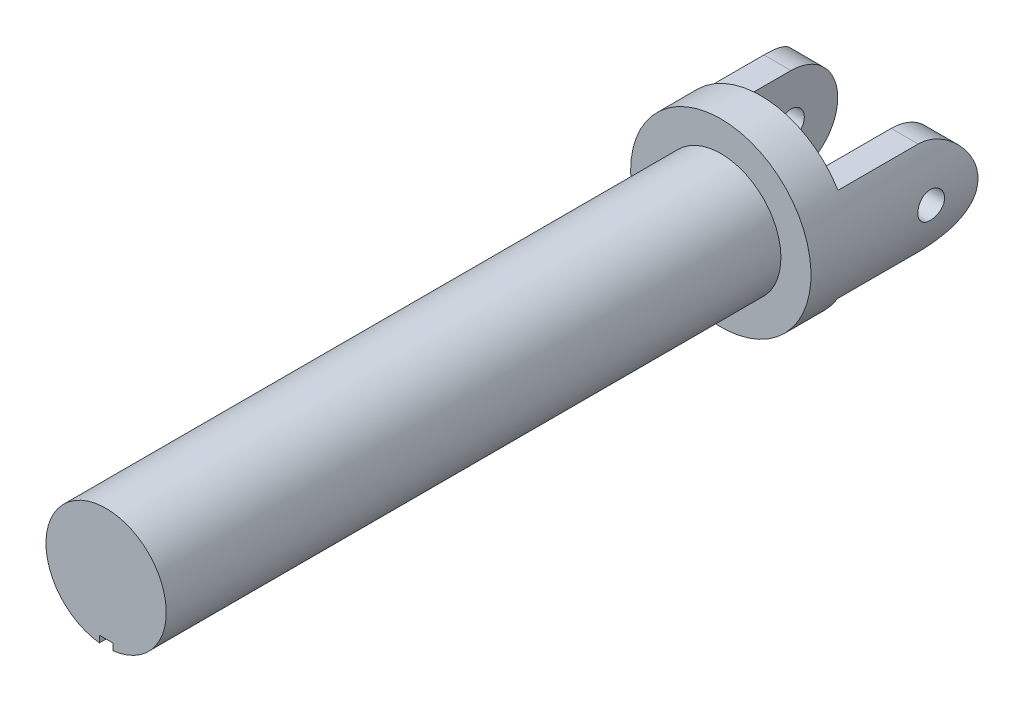
from build123d import *

# Parameters (mm, degrees)
SKETCH1_R                = 4.5
YOKE_DEPTH               = 23
SKETCH2_R                = 6.75
U_JOINT_BASE_DEPTH       = 3
U_JOINT_STANDUPS_DEPTH   = 9.5
STANDUP_ROUND_DEPTH      = 7.75
STANDUP_ROUND_DEPTH_BACK = 7.75
SKETCH5_R                = 1
BALL_HOLES_DEPTH         = 7.75
BALL_HOLES_DEPTH_BACK    = 7.75
KEYWAY_DEPTH             = 46


with BuildPart() as part:
    # Sketch1 → Yoke (new body, symmetric)
    with BuildSketch(Plane.XY):
        Circle(SKETCH1_R)
    extrude(amount=YOKE_DEPTH, both=True)

    # Sketch2 → U Joint Base (add)
    with BuildSketch(Plane(origin=(0, 0, -23), x_dir=(-1, 0, 0), z_dir=(0, 0, -1))):
        Circle(SKETCH2_R)
    extrude(amount=U_JOINT_BASE_DEPTH)

    # Sketch3 → U Joint Standups (add)
    with BuildSketch(Plane(origin=(0, 0, -26), x_dir=(-1, 0, 0), z_dir=(0, 0, -1))):
        with BuildLine():
            Line((-5.771698, 3.5), (-3.75, 3.5))
            Line((-3.75, 3.5), (-3.75, -3.5))
            Line((-3.75, -3.5), (-5.771698, -3.5))
            ThreePointArc((-5.771698, -3.5), (-6.75, 0), (-5.771698, 3.5))
        make_face()
        with BuildLine():
            Line((3.75, -3.5), (3.75, 3.5))
            Line((3.75, 3.5), (5.771698, 3.5))
            ThreePointArc((5.771698, 3.5), (6.75, 0), (5.771698, -3.5))
            Line((5.771698, -3.5), (3.75, -3.5))
        make_face()
    extrude(amount=U_JOINT_STANDUPS_DEPTH)

    # Sketch4 → Standup Round (cut, two sides)
    with BuildSketch(Plane(origin=(0, 0, 0), x_dir=(0, 0, -1), z_dir=(1, 0, 0))) as standup_round_sk:
        with BuildLine():
            ThreePointArc((32, -3.5), (34.474874, -2.474874), (35.5, 0))
            Line((35.5, 0), (35.5, -3.5))
            Line((35.5, -3.5), (32, -3.5))
        make_face()
        with BuildLine():
            ThreePointArc((35.5, 0), (34.474874, 2.474874), (32, 3.5))
            Line((32, 3.5), (35.5, 3.5))
            Line((35.5, 3.5), (35.5, 0))
        make_face()
    extrude(amount=STANDUP_ROUND_DEPTH, mode=Mode.SUBTRACT)
    extrude(standup_round_sk.sketch, amount=-STANDUP_ROUND_DEPTH_BACK, mode=Mode.SUBTRACT)

    # Sketch5 → Ball Holes (cut, two sides)
    with BuildSketch(Plane(origin=(0, 0, 0), x_dir=(0, 0, -1), z_dir=(1, 0, 0))) as ball_holes_sk:
        with Locations((32, 0)):
            Circle(SKETCH5_R)
    extrude(amount=BALL_HOLES_DEPTH, mode=Mode.SUBTRACT)
    extrude(ball_holes_sk.sketch, amount=-BALL_HOLES_DEPTH_BACK, mode=Mode.SUBTRACT)

    # Sketch6 → Keyway (cut)
    with BuildSketch(Plane.XY.offset(23)):
        Polygon((0.5, -4.472136), (0.5, -4.702036), (-0.5, -4.702036), (-0.5, -4.472136), (-0.5, -3.972136), (0.5, -3.972136), align=None)
    extrude(amount=-KEYWAY_DEPTH, mode=Mode.SUBTRACT)


solid = part.part
